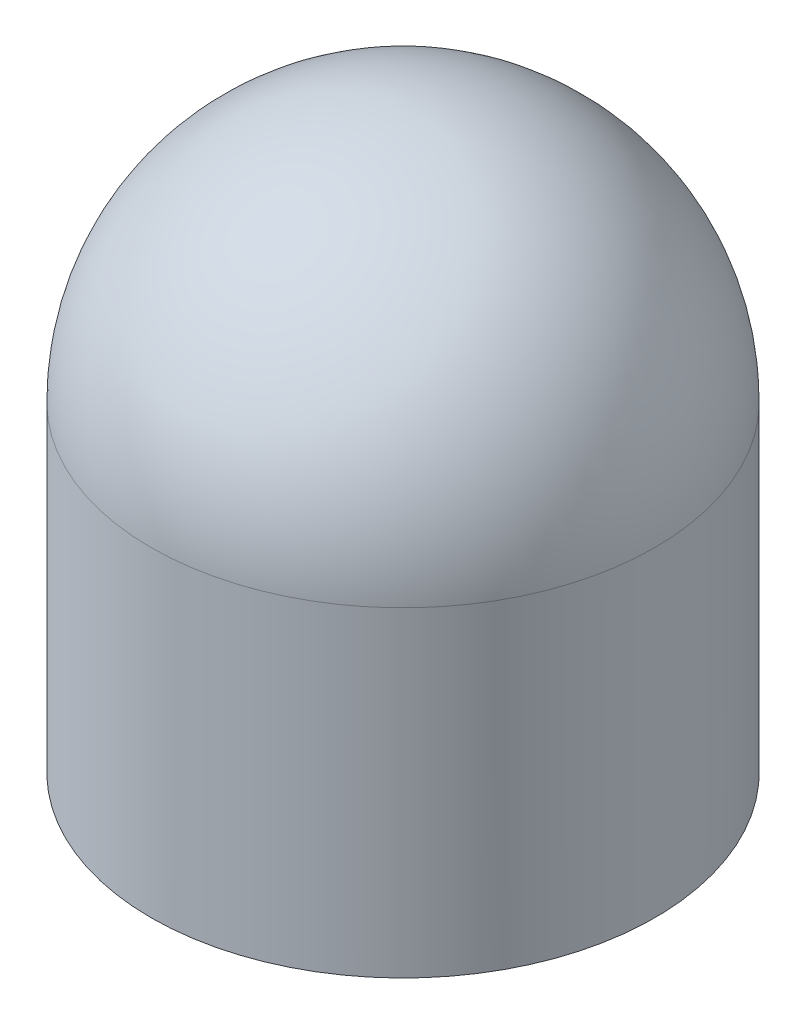
from build123d import *

# Parameters (mm, degrees)
SKETCH1_W           = 3.175
SKETCH1_H           = 12.7
SKETCH3_R           = 67.061060388
SKETCH3_R_2         = 66.267310388
BOSS_EXTRUDE1_DEPTH = 12.7
FILLET2_R           = 0.79375


with BuildPart() as part:
    # Sketch1 → Revolve3 (revolve)
    with BuildSketch(Plane.XY):
        with BuildLine():
            Line((69.85, 0), (69.85, 76.2))
            ThreePointArc((69.85, 76.2), (49.391408666, 125.591408666), (0, 146.05))
            Line((0, 146.05), (0, 139.7))
            ThreePointArc((0, 139.7), (44.901280605, 121.101280605), (63.5, 76.2))
            Line((63.5, 76.2), (63.5, 0))
            Line((63.5, 0), (69.85, 0))
        make_face()
        with Locations((68.2625, -6.35)):
            Rectangle(SKETCH1_W, SKETCH1_H)
    revolve(axis=Axis((0, 146.05, 0), (0, -1, 0)))

    # Sketch3 → Boss-Extrude1 (add)
    with BuildSketch(Plane(origin=(0, 0, 0), x_dir=(-1, 0, 0), z_dir=(0, -1, 0))):
        Circle(SKETCH3_R)
        Circle(SKETCH3_R_2, mode=Mode.SUBTRACT)
    extrude(amount=BOSS_EXTRUDE1_DEPTH)

    # Fillet2
    fillet2_edges = [part.edges().sort_by_distance(p)[0] for p in [
        (66.267310388, -12.7, 0),
    ]]
    fillet(fillet2_edges, radius=FILLET2_R)


solid = part.part
